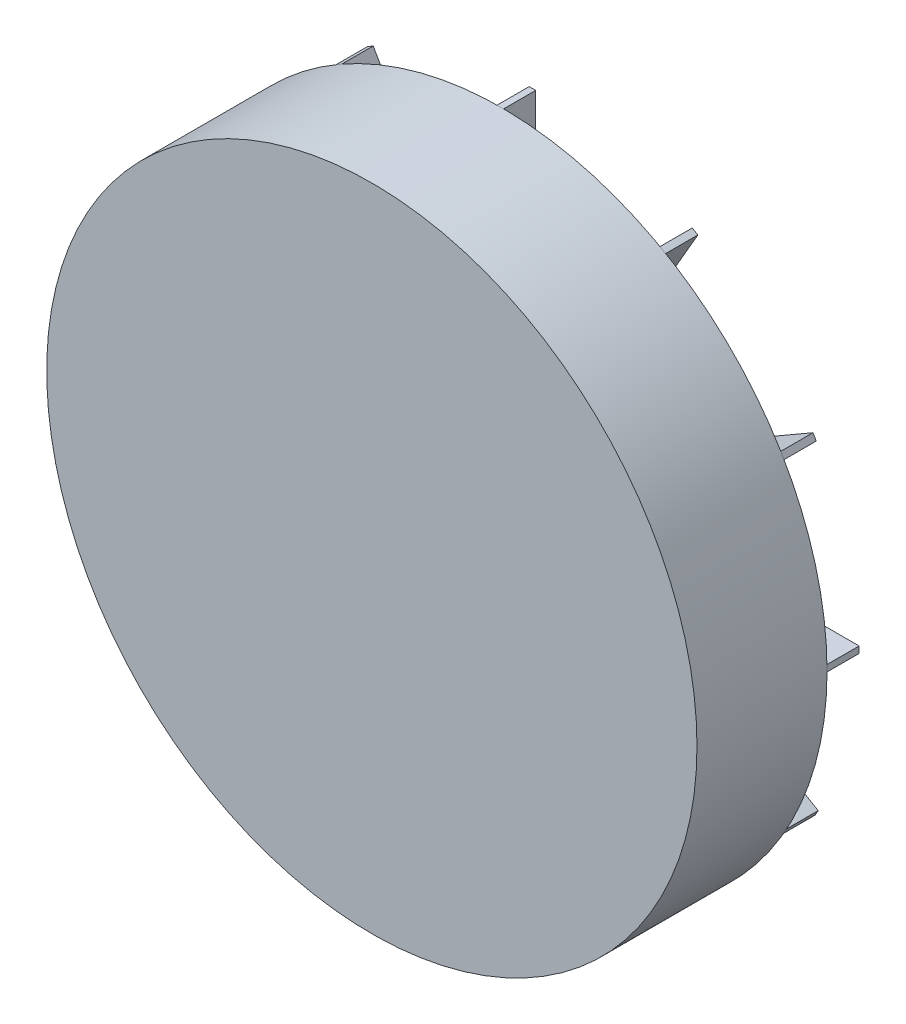
from build123d import *

# Parameters (mm, degrees)
SKETCH1_R           = 100
BOSS_EXTRUDE1_DEPTH = 40
BOSS_EXTRUDE4_DEPTH = 10


with BuildPart() as part:
    # Sketch1 → Boss-Extrude1 (new body)
    with BuildSketch(Plane.XY):
        Circle(SKETCH1_R)
    extrude(amount=BOSS_EXTRUDE1_DEPTH)

    # Sketch3 → Boss-Extrude4 (add)
    with BuildSketch(Plane.XY):
        Polygon((-0.602668663, 0.79799153), (-36.821347212, -26.555510029), (-38.629353201, -24.161535438), (-60.970804607, -46.04709685), (-33.808003897, -30.545467681), (-35.616009886, -28.15149309), (0.602668663, -0.79799153), align=None)
        with BuildLine():
            Line((-1.602668663, 99.861033349), (-1.602668663, 82.422716301))
            ThreePointArc((-1.602668663, 82.422716301), (-0.602668663, 81.422716301), (0.397331337, 82.422716301))
            Line((0.397331337, 82.422716301), (0.397331337, 99.861033349))
            Line((0.397331337, 99.861033349), (-1.602668663, 99.861033349))
        make_face()
        with BuildLine():
            Line((48.542564899, 87.28352606), (39.823406374, 72.181500497))
            ThreePointArc((39.823406374, 72.181500497), (40.189431778, 70.815475093), (41.555457182, 71.181500497))
            Line((41.555457182, 71.181500497), (50.274615706, 86.28352606))
            Line((50.274615706, 86.28352606), (48.542564899, 87.28352606))
        make_face()
        with BuildLine():
            Line((85.680857397, 51.318468451), (70.578831834, 42.599309926))
            ThreePointArc((70.578831834, 42.599309926), (70.21280643, 41.233284522), (71.578831834, 40.867259119))
            Line((71.578831834, 40.867259119), (86.680857397, 49.586417643))
            Line((86.680857397, 49.586417643), (85.680857397, 51.318468451))
        make_face()
        with BuildLine():
            Line((99.861033349, 1.602668663), (82.422716301, 1.602668663))
            ThreePointArc((82.422716301, 1.602668663), (81.422716301, 0.602668663), (82.422716301, -0.397331337))
            Line((82.422716301, -0.397331337), (99.861033349, -0.397331337))
            Line((99.861033349, -0.397331337), (99.861033349, 1.602668663))
        make_face()
        with BuildLine():
            Line((87.28352606, -48.542564899), (72.181500497, -39.823406374))
            ThreePointArc((72.181500497, -39.823406374), (70.815475093, -40.189431778), (71.181500497, -41.555457182))
            Line((71.181500497, -41.555457182), (86.28352606, -50.274615706))
            Line((86.28352606, -50.274615706), (87.28352606, -48.542564899))
        make_face()
        with BuildLine():
            Line((51.318468451, -85.680857397), (42.599309926, -70.578831834))
            ThreePointArc((42.599309926, -70.578831834), (41.233284522, -70.21280643), (40.867259119, -71.578831834))
            Line((40.867259119, -71.578831834), (49.586417643, -86.680857397))
            Line((49.586417643, -86.680857397), (51.318468451, -85.680857397))
        make_face()
        with BuildLine():
            Line((1.602668663, -99.861033349), (1.602668663, -82.422716301))
            ThreePointArc((1.602668663, -82.422716301), (0.602668663, -81.422716301), (-0.397331337, -82.422716301))
            Line((-0.397331337, -82.422716301), (-0.397331337, -99.861033349))
            Line((-0.397331337, -99.861033349), (1.602668663, -99.861033349))
        make_face()
        with BuildLine():
            Line((-48.542564899, -87.28352606), (-39.823406374, -72.181500497))
            ThreePointArc((-39.823406374, -72.181500497), (-40.189431778, -70.815475093), (-41.555457182, -71.181500497))
            Line((-41.555457182, -71.181500497), (-50.274615706, -86.28352606))
            Line((-50.274615706, -86.28352606), (-48.542564899, -87.28352606))
        make_face()
        with BuildLine():
            Line((-85.680857397, -51.318468451), (-70.578831834, -42.599309926))
            ThreePointArc((-70.578831834, -42.599309926), (-70.21280643, -41.233284522), (-71.578831834, -40.867259119))
            Line((-71.578831834, -40.867259119), (-86.680857397, -49.586417643))
            Line((-86.680857397, -49.586417643), (-85.680857397, -51.318468451))
        make_face()
        with BuildLine():
            Line((-99.861033349, -1.602668663), (-82.422716301, -1.602668663))
            ThreePointArc((-82.422716301, -1.602668663), (-81.422716301, -0.602668663), (-82.422716301, 0.397331337))
            Line((-82.422716301, 0.397331337), (-99.861033349, 0.397331337))
            Line((-99.861033349, 0.397331337), (-99.861033349, -1.602668663))
        make_face()
        with BuildLine():
            Line((-87.28352606, 48.542564899), (-72.181500497, 39.823406374))
            ThreePointArc((-72.181500497, 39.823406374), (-70.815475093, 40.189431778), (-71.181500497, 41.555457182))
            Line((-71.181500497, 41.555457182), (-86.28352606, 50.274615706))
            Line((-86.28352606, 50.274615706), (-87.28352606, 48.542564899))
        make_face()
        with BuildLine():
            Line((-51.318468451, 85.680857397), (-42.599309926, 70.578831834))
            ThreePointArc((-42.599309926, 70.578831834), (-41.233284522, 70.21280643), (-40.867259119, 71.578831834))
            Line((-40.867259119, 71.578831834), (-49.586417643, 86.680857397))
            Line((-49.586417643, 86.680857397), (-51.318468451, 85.680857397))
        make_face()
    extrude(amount=-BOSS_EXTRUDE4_DEPTH)


solid = part.part
